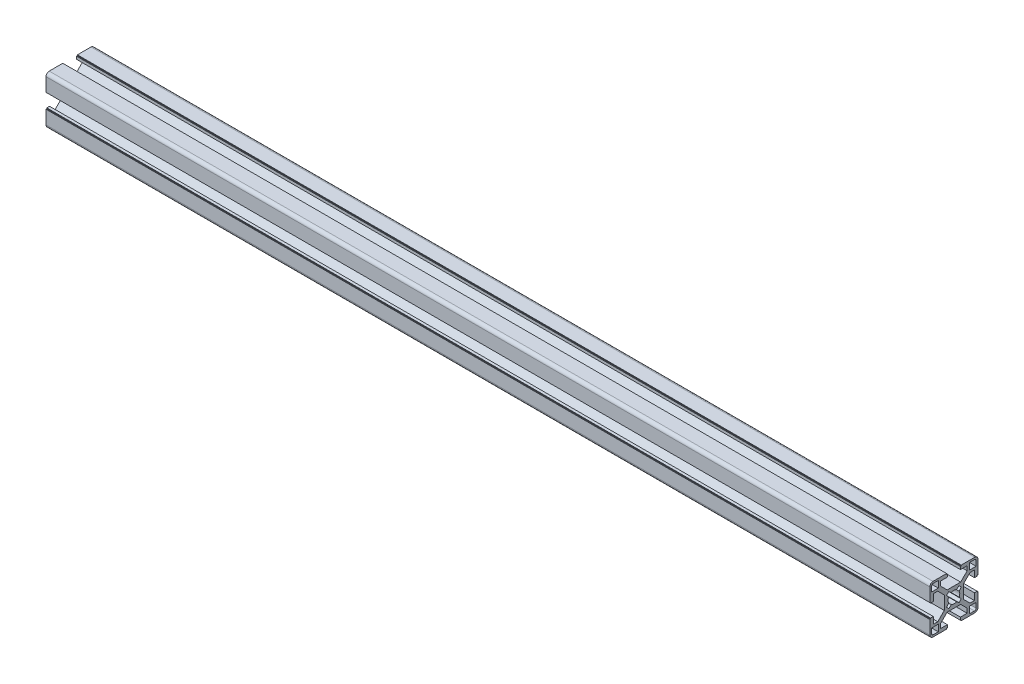
from build123d import *

# Parameters (mm, degrees)
BR_EXTRUDE_DEPTH      = 275
BR_EXTRUDE_DEPTH_BACK = 275


with BuildPart() as part:
    # Sketch2 → BR_Extrude (new body, two sides)
    with BuildSketch(Plane(origin=(0, 0, 0), x_dir=(0, 0, -1), z_dir=(1, 0, 0))) as br_extrude_sk:
        with BuildLine():
            Line((-6, 4.196877708), (-10.053122292, 8.25))
            Line((-10.053122292, 8.25), (-12.8, 8.25))
            Line((-12.8, 8.25), (-12.800036742, 4.05))
            Line((-12.800036742, 4.05), (-14.5, 4.05))
            Line((-14.5, 4.05), (-14.5, 4.55))
            Line((-14.5, 4.55), (-15, 4.55))
            Line((-15, 4.55), (-15, 13))
            ThreePointArc((-15, 13), (-14.414213562, 14.414213562), (-13, 15))
            Line((-13, 15), (-4.55, 15))
            Line((-4.55, 15), (-4.55, 14.5))
            Line((-4.55, 14.5), (-4.05, 14.5))
            Line((-4.05, 14.5), (-4.05, 12.800036742))
            Line((-4.05, 12.800036742), (-8.25, 12.8))
            Line((-8.25, 12.8), (-8.25, 10.053122292))
            Line((-8.25, 10.053122292), (-4.196877708, 6))
            Line((-4.196877708, 6), (4.196877708, 6))
            Line((4.196877708, 6), (8.25, 10.053122292))
            Line((8.25, 10.053122292), (8.25, 12.8))
            Line((8.25, 12.8), (4.05, 12.800036742))
            Line((4.05, 12.800036742), (4.05, 14.5))
            Line((4.05, 14.5), (4.55, 14.5))
            Line((4.55, 14.5), (4.55, 15))
            Line((4.55, 15), (13, 15))
            ThreePointArc((13, 15), (14.414213562, 14.414213562), (15, 13))
            Line((15, 13), (15, 4.55))
            Line((15, 4.55), (14.5, 4.55))
            Line((14.5, 4.55), (14.5, 4.05))
            Line((14.5, 4.05), (12.800036742, 4.05))
            Line((12.800036742, 4.05), (12.8, 8.25))
            Line((12.8, 8.25), (10.053122292, 8.25))
            Line((10.053122292, 8.25), (6, 4.196877708))
            Line((6, 4.196877708), (6, -4.196877708))
            Line((6, -4.196877708), (10.053122292, -8.25))
            Line((10.053122292, -8.25), (12.8, -8.25))
            Line((12.8, -8.25), (12.800036742, -4.05))
            Line((12.800036742, -4.05), (14.5, -4.05))
            Line((14.5, -4.05), (14.5, -4.55))
            Line((14.5, -4.55), (15, -4.55))
            Line((15, -4.55), (15, -13))
            ThreePointArc((15, -13), (14.414213562, -14.414213562), (13, -15))
            Line((13, -15), (4.55, -15))
            Line((4.55, -15), (4.55, -14.5))
            Line((4.55, -14.5), (4.05, -14.5))
            Line((4.05, -14.5), (4.05, -12.800036742))
            Line((4.05, -12.800036742), (8.25, -12.8))
            Line((8.25, -12.8), (8.25, -10.053122292))
            Line((8.25, -10.053122292), (4.196877708, -6))
            Line((4.196877708, -6), (-4.196877708, -6))
            Line((-4.196877708, -6), (-8.25, -10.053122292))
            Line((-8.25, -10.053122292), (-8.25, -12.8))
            Line((-8.25, -12.8), (-4.05, -12.800036742))
            Line((-4.05, -12.800036742), (-4.05, -14.5))
            Line((-4.05, -14.5), (-4.55, -14.5))
            Line((-4.55, -14.5), (-4.55, -15))
            Line((-4.55, -15), (-13, -15))
            ThreePointArc((-13, -15), (-14.414213562, -14.414213562), (-15, -13))
            Line((-15, -13), (-15, -4.55))
            Line((-15, -4.55), (-14.5, -4.55))
            Line((-14.5, -4.55), (-14.5, -4.05))
            Line((-14.5, -4.05), (-12.800036742, -4.05))
            Line((-12.800036742, -4.05), (-12.8, -8.25))
            Line((-12.8, -8.25), (-10.053122292, -8.25))
            Line((-10.053122292, -8.25), (-6, -4.196877708))
            Line((-6, -4.196877708), (-6, 4.196877708))
        make_face()
        with BuildLine():
            Line((-13.85, -9.7), (-13.85, -12.85))
            ThreePointArc((-13.85, -12.85), (-13.557106781, -13.557106781), (-12.85, -13.85))
            Line((-12.85, -13.85), (-9.7, -13.85))
            Line((-9.7, -13.85), (-9.7, -9.7))
            Line((-9.7, -9.7), (-13.85, -9.7))
        make_face(mode=Mode.SUBTRACT)
        with BuildLine():
            Line((9.7, -13.85), (12.85, -13.85))
            ThreePointArc((12.85, -13.85), (13.557106781, -13.557106781), (13.85, -12.85))
            Line((13.85, -12.85), (13.85, -9.7))
            Line((13.85, -9.7), (9.7, -9.7))
            Line((9.7, -9.7), (9.7, -13.85))
        make_face(mode=Mode.SUBTRACT)
        with BuildLine():
            Line((13.85, 9.7), (13.85, 12.85))
            ThreePointArc((13.85, 12.85), (13.557106781, 13.557106781), (12.85, 13.85))
            Line((12.85, 13.85), (9.7, 13.85))
            Line((9.7, 13.85), (9.7, 9.7))
            Line((9.7, 9.7), (13.85, 9.7))
        make_face(mode=Mode.SUBTRACT)
        with BuildLine():
            Line((-9.7, 13.85), (-12.85, 13.85))
            ThreePointArc((-12.85, 13.85), (-13.557106781, 13.557106781), (-13.85, 12.85))
            Line((-13.85, 12.85), (-13.85, 9.7))
            Line((-13.85, 9.7), (-9.7, 9.7))
            Line((-9.7, 9.7), (-9.7, 13.85))
        make_face(mode=Mode.SUBTRACT)
        with BuildLine():
            Line((-3.272394192, -1.616767223), (-4.59052283, -3.187651763))
            Line((-4.59052283, -3.187651763), (-3.187651763, -4.59052283))
            Line((-3.187651763, -4.59052283), (-1.616767223, -3.272394192))
            ThreePointArc((-1.616767223, -3.272394192), (0, -3.65), (1.616767223, -3.272394192))
            Line((1.616767223, -3.272394192), (3.187651763, -4.59052283))
            Line((3.187651763, -4.59052283), (4.59052283, -3.187651763))
            Line((4.59052283, -3.187651763), (3.272394192, -1.616767223))
            ThreePointArc((3.272394192, -1.616767223), (3.65, 0), (3.272394192, 1.616767223))
            Line((3.272394192, 1.616767223), (4.59052283, 3.187651763))
            Line((4.59052283, 3.187651763), (3.187651763, 4.59052283))
            Line((3.187651763, 4.59052283), (1.616767223, 3.272394192))
            ThreePointArc((1.616767223, 3.272394192), (0, 3.65), (-1.616767223, 3.272394192))
            Line((-1.616767223, 3.272394192), (-3.187651763, 4.59052283))
            Line((-3.187651763, 4.59052283), (-4.59052283, 3.187651763))
            Line((-4.59052283, 3.187651763), (-3.272394192, 1.616767223))
            ThreePointArc((-3.272394192, 1.616767223), (-3.65, 0), (-3.272394192, -1.616767223))
        make_face(mode=Mode.SUBTRACT)
    extrude(amount=BR_EXTRUDE_DEPTH)
    extrude(br_extrude_sk.sketch, amount=-BR_EXTRUDE_DEPTH_BACK)


solid = part.part
